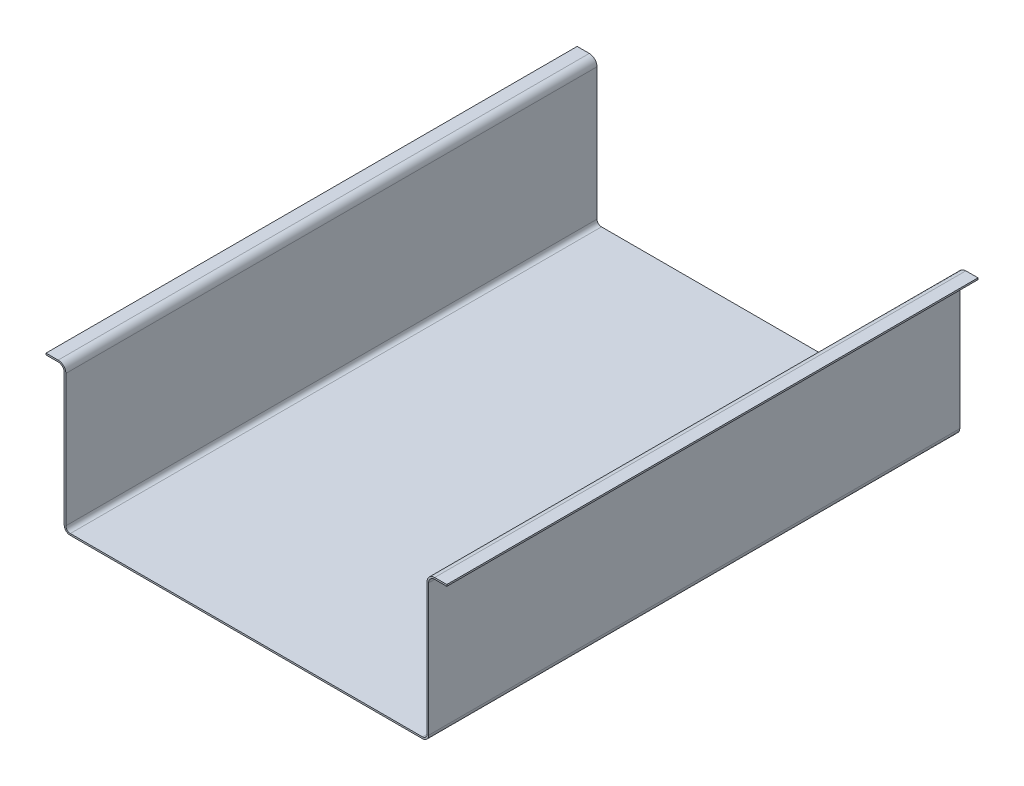
from build123d import *

# Parameters (mm, degrees)
BASE_DEPTH = 555.3837


with BuildPart() as part:
    # Sketch1 → Base (new body, symmetric)
    with BuildSketch(Plane.XY):
        with BuildLine():
            Line((-377.5837, 12.7), (-377.5837, 288.6837))
            ThreePointArc((-377.5837, 288.6837), (-382.304054982, 300.079645018), (-393.7, 304.8))
            Line((-393.7, 304.8), (-419.1, 304.8))
            Line((-419.1, 304.8), (-419.1, 301.3837))
            Line((-419.1, 301.3837), (-393.7, 301.3837))
            ThreePointArc((-393.7, 301.3837), (-384.719743879, 297.663956121), (-381, 288.6837))
            Line((-381, 288.6837), (-381, 12.7))
            ThreePointArc((-381, 12.7), (-377.280256121, 3.719743879), (-368.3, 0))
            Line((-368.3, 0), (368.3, 0))
            ThreePointArc((368.3, 0), (377.280256121, 3.719743879), (381, 12.7))
            Line((381, 12.7), (381, 288.6837))
            ThreePointArc((381, 288.6837), (384.719743879, 297.663956121), (393.7, 301.3837))
            Line((393.7, 301.3837), (419.1, 301.3837))
            Line((419.1, 301.3837), (419.1, 304.8))
            Line((419.1, 304.8), (393.7, 304.8))
            ThreePointArc((393.7, 304.8), (382.304054982, 300.079645018), (377.5837, 288.6837))
            Line((377.5837, 288.6837), (377.5837, 12.7))
            ThreePointArc((377.5837, 12.7), (374.864567225, 6.135432775), (368.3, 3.4163))
            Line((368.3, 3.4163), (-368.3, 3.4163))
            ThreePointArc((-368.3, 3.4163), (-374.864567225, 6.135432775), (-377.5837, 12.7))
        make_face()
    extrude(amount=BASE_DEPTH, both=True)


solid = part.part
